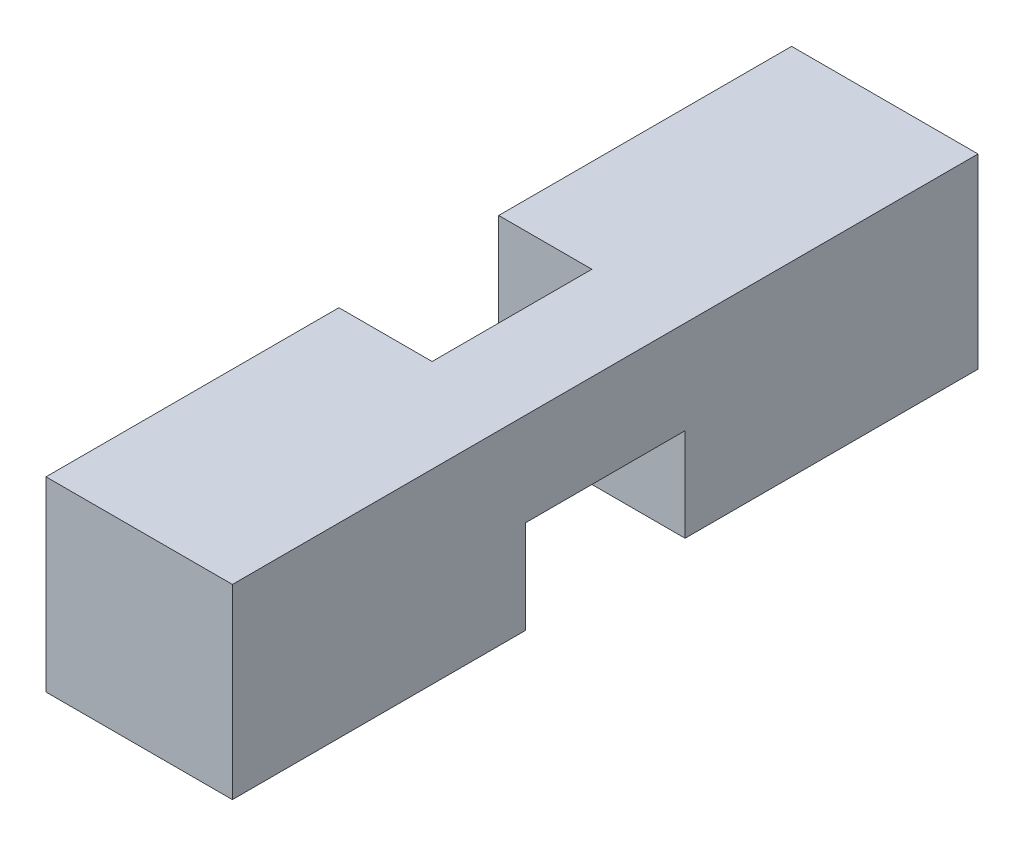
from build123d import *

# Parameters (mm, degrees)
SKETCH1_W               = 3.5
SKETCH1_H               = 3.5
BOSS_EXTRUDE1_DEPTH     = 14
CUT_EXTRUDE1_DEPTH      = 1.5
CUT_EXTRUDE1_DEPTH_BACK = 1.5


with BuildPart() as part:
    # Sketch1 → Boss-Extrude1 (new body)
    with BuildSketch(Plane.XY):
        Rectangle(SKETCH1_W, SKETCH1_H)
    extrude(amount=BOSS_EXTRUDE1_DEPTH)

    # Sketch2 → Cut-Extrude1 (cut, two sides)
    with BuildSketch(Plane.XY.offset(7)) as cut_extrude1_sk:
        with BuildLine():
            Line((1.75, -1.75), (1.75, 0))
            ThreePointArc((1.75, 0), (0.512563133, 0.512563133), (0, 1.75))
            Line((0, 1.75), (-1.75, 1.75))
            Line((-1.75, 1.75), (-1.75, -1.75))
            Line((-1.75, -1.75), (1.75, -1.75))
        make_face()
    extrude(amount=CUT_EXTRUDE1_DEPTH, mode=Mode.SUBTRACT)
    extrude(cut_extrude1_sk.sketch, amount=-CUT_EXTRUDE1_DEPTH_BACK, mode=Mode.SUBTRACT)


solid = part.part
